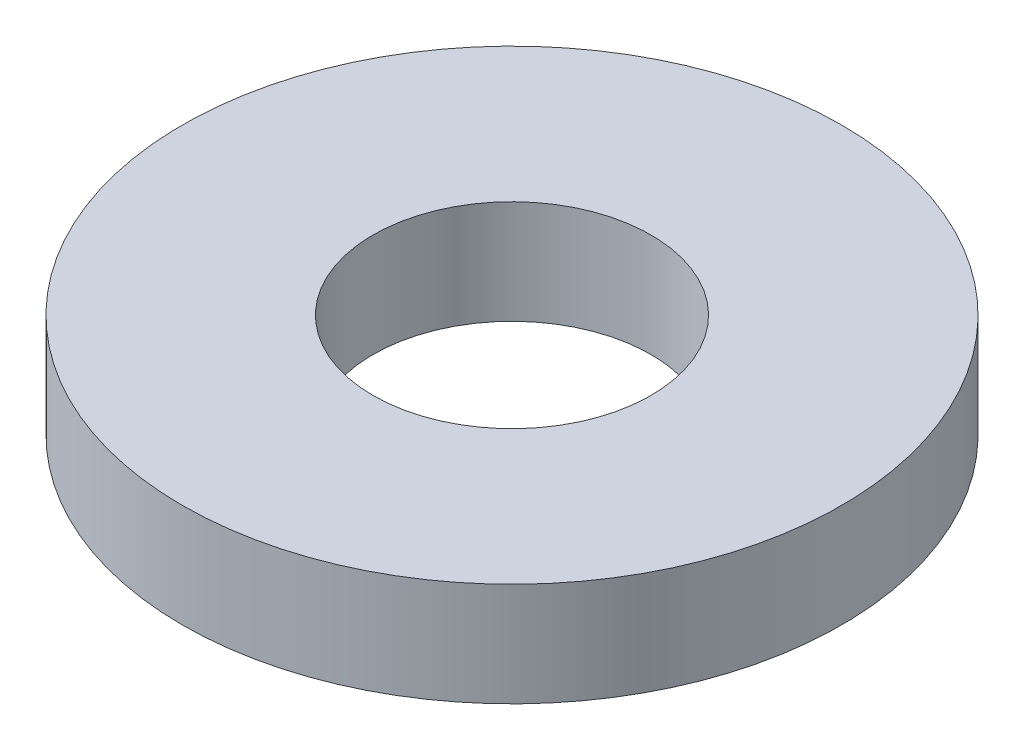
from build123d import *

# Parameters (mm, degrees)
SKETCH1_R           = 17.78
SKETCH1_R_2         = 7.5
BOSS_EXTRUDE1_DEPTH = 5.588


with BuildPart() as part:
    # Sketch1 → Boss-Extrude1 (new body)
    with BuildSketch(Plane(origin=(0, 0, 0), x_dir=(1, 0, 0), z_dir=(0, 1, 0))):
        Circle(SKETCH1_R)
        Circle(SKETCH1_R_2, mode=Mode.SUBTRACT)
    extrude(amount=BOSS_EXTRUDE1_DEPTH)


solid = part.part
